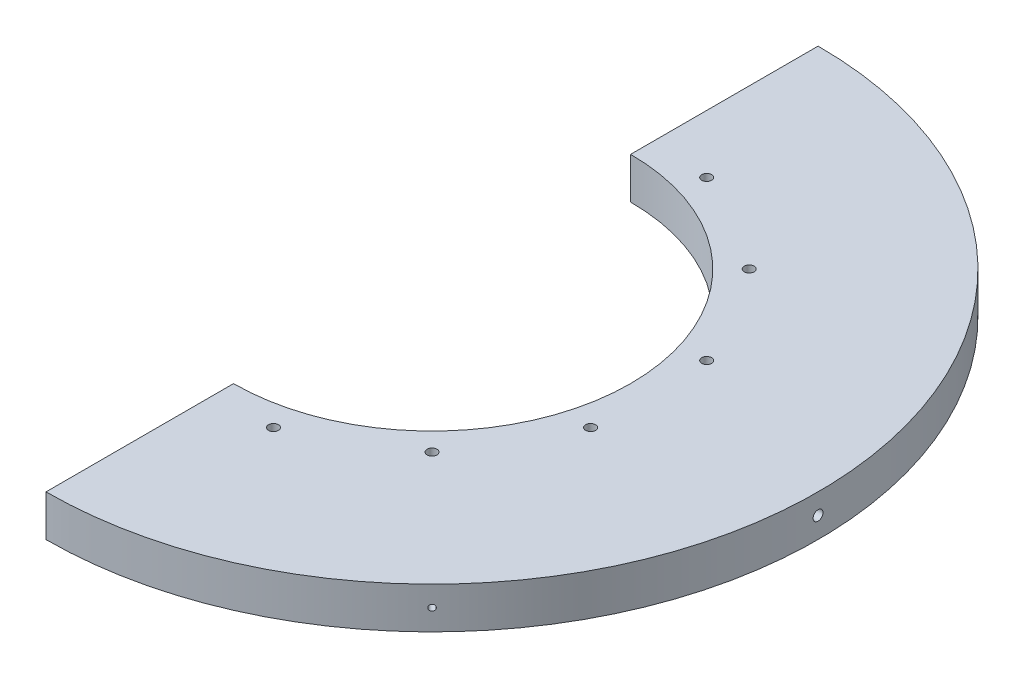
from build123d import *

# Parameters (mm, degrees)
SKETCH1_R               = 88.9
BOSS_EXTRUDE1_DEPTH     = 9.525
SKETCH2_R               = 45.72
CUT_EXTRUDE1_DEPTH      = 12.7
SKETCH3_R               = 1.143
CUT_EXTRUDE2_DEPTH      = 12.7
CUT_EXTRUDE3_DEPTH      = 127.083883288
CUT_EXTRUDE3_DEPTH_BACK = 127.083883288
CIRPATTERN1_COUNT       = 12
SKETCH6_R               = 1.143
CUT_EXTRUDE4_DEPTH      = 25.4
SKETCH7_R               = 0.6985
CUT_EXTRUDE5_DEPTH      = 3.175
CIRPATTERN2_COUNT       = 4


with BuildPart() as part:
    # Sketch1 → Boss-Extrude1 (new body)
    with BuildSketch(Plane(origin=(0, 0, 0), x_dir=(1, 0, 0), z_dir=(0, 1, 0))):
        with Locations(Location((0, 0, 0), (0, 0, 90))):
            Circle(SKETCH1_R)
    extrude(amount=BOSS_EXTRUDE1_DEPTH)

    # Sketch2 → Cut-Extrude1 (cut)
    with BuildSketch(Plane(origin=(0, 9.525, 0), x_dir=(1, 0, 0), z_dir=(0, 1, 0))):
        with Locations(Location((0, 0, 0), (0, 0, 270))):
            Circle(SKETCH2_R)
    extrude(amount=-CUT_EXTRUDE1_DEPTH, mode=Mode.SUBTRACT)

    # Sketch3 → Cut-Extrude2 (cut)
    with BuildSketch(Plane(origin=(0, 9.525, 0), x_dir=(1, 0, 0), z_dir=(0, 1, 0))):
        with Locations(Location((13.364949615, 49.878671003, 0), (0, 0, 270))):
            Circle(SKETCH3_R)
    cut_extrude2 = extrude(amount=-CUT_EXTRUDE2_DEPTH, mode=Mode.SUBTRACT)

    # Sketch5 → Cut-Extrude3 (cut, two sides)
    with BuildSketch(Plane(origin=(0, 9.525, 0), x_dir=(1, 0, 0), z_dir=(0, 1, 0))) as cut_extrude3_sk:
        Polygon((0, 139.125590331), (0, -130.538836117), (-200.055019192, 4.293377107), align=None)
    extrude(amount=CUT_EXTRUDE3_DEPTH, mode=Mode.SUBTRACT)
    extrude(cut_extrude3_sk.sketch, amount=-CUT_EXTRUDE3_DEPTH_BACK, mode=Mode.SUBTRACT)

    # CirPattern1: Cut-Extrude2 ×12 about axis
    cirpattern1_axis = Axis((0, 9.525, 0), (0, 1, 0))
    for i in range(1, CIRPATTERN1_COUNT):
        add(cut_extrude2.rotate(cirpattern1_axis, i * 360 / CIRPATTERN1_COUNT), mode=Mode.SUBTRACT)

    # Sketch6 → Cut-Extrude4 (cut)
    with BuildSketch(Plane(origin=(88.9, 0, 0), x_dir=(0, 0, -1), z_dir=(1, 0, 0))):
        with Locations((0, 4.826)):
            Circle(SKETCH6_R)
    extrude(amount=-CUT_EXTRUDE4_DEPTH, mode=Mode.SUBTRACT)

    # Sketch7 → Cut-Extrude5 (cut)
    with BuildSketch(Plane(origin=(62.861792847, 0, 62.861792847), x_dir=(0, -1, 0), z_dir=(0.7071067811865464, 0, 0.7071067811865488))):
        with Locations(Location((-4.826, 0, 0), (0, 0, 90))):
            Circle(SKETCH7_R)
    cut_extrude5 = extrude(amount=-CUT_EXTRUDE5_DEPTH, mode=Mode.SUBTRACT)

    # CirPattern2: Cut-Extrude5 ×4 about axis
    cirpattern2_axis = Axis((0, 9.525, 0), (0, 1, 0))
    for i in range(1, CIRPATTERN2_COUNT):
        add(cut_extrude5.rotate(cirpattern2_axis, i * 360 / CIRPATTERN2_COUNT), mode=Mode.SUBTRACT)


solid = part.part
